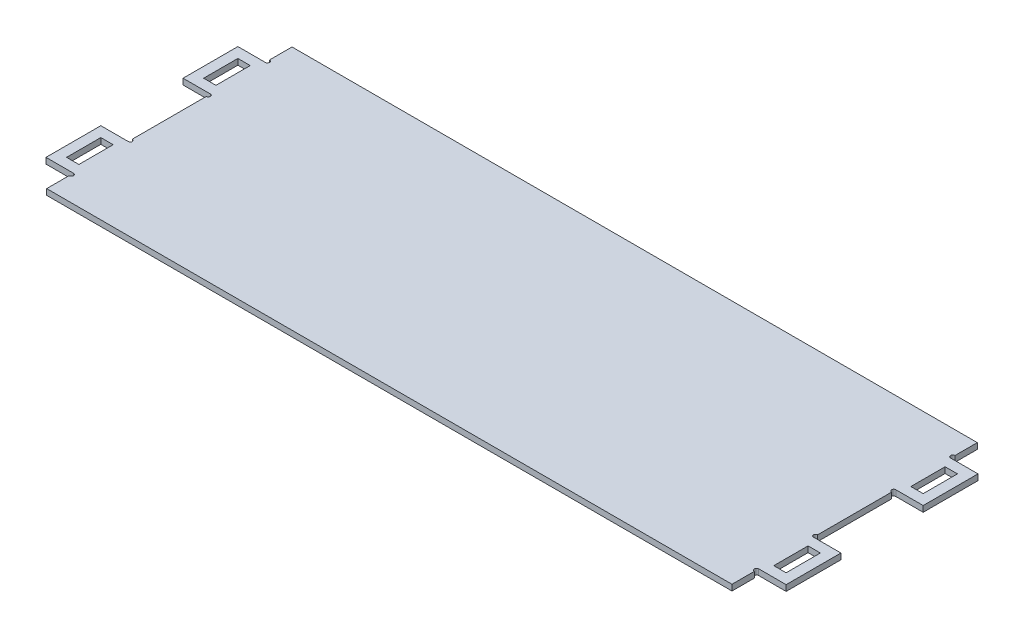
from build123d import *

# Parameters (mm, degrees)
SKETCH1_W           = 18
SKETCH1_H           = 50
BOSS_EXTRUDE1_DEPTH = 4.3


with BuildPart() as part:
    # Sketch1 → Boss-Extrude1 (new body, symmetric)
    with BuildSketch(Plane(origin=(0, 0, 0), x_dir=(1, 0, 0), z_dir=(0, 1, 0))):
        with BuildLine():
            Line((-500, 179), (500, 179))
            Line((500, 179), (500, 146.36))
            ThreePointArc((500, 146.36), (496.82, 143.18), (500, 140))
            Line((500, 140), (540, 140))
            Line((540, 140), (540, 60))
            Line((540, 60), (500, 60))
            ThreePointArc((500, 60), (497, 57), (500, 54))
            Line((500, 54), (500, -54))
            ThreePointArc((500, -54), (497, -57), (500, -60))
            Line((500, -60), (540, -60))
            Line((540, -60), (540, -140))
            Line((540, -140), (500, -140))
            ThreePointArc((500, -140), (496.82, -143.18), (500, -146.36))
            Line((500, -146.36), (500, -179))
            Line((500, -179), (-500, -179))
            Line((-500, -179), (-500, -146.36))
            ThreePointArc((-500, -146.36), (-496.82, -143.18), (-500, -140))
            Line((-500, -140), (-540, -140))
            Line((-540, -140), (-540, -60))
            Line((-540, -60), (-500, -60))
            ThreePointArc((-500, -60), (-497, -57), (-500, -54))
            Line((-500, -54), (-500, 54))
            ThreePointArc((-500, 54), (-497, 57), (-500, 60))
            Line((-500, 60), (-540, 60))
            Line((-540, 60), (-540, 140))
            Line((-540, 140), (-500, 140))
            ThreePointArc((-500, 140), (-496.82, 143.18), (-500, 146.36))
            Line((-500, 146.36), (-500, 179))
        make_face()
        with Locations((-516, 100)):
            Rectangle(SKETCH1_W, SKETCH1_H, mode=Mode.SUBTRACT)
        with Locations((-516, -100)):
            Rectangle(SKETCH1_W, SKETCH1_H, mode=Mode.SUBTRACT)
        with Locations((516, -100)):
            Rectangle(SKETCH1_W, SKETCH1_H, mode=Mode.SUBTRACT)
        with Locations((516, 100)):
            Rectangle(SKETCH1_W, SKETCH1_H, mode=Mode.SUBTRACT)
    extrude(amount=BOSS_EXTRUDE1_DEPTH, both=True)


solid = part.part
